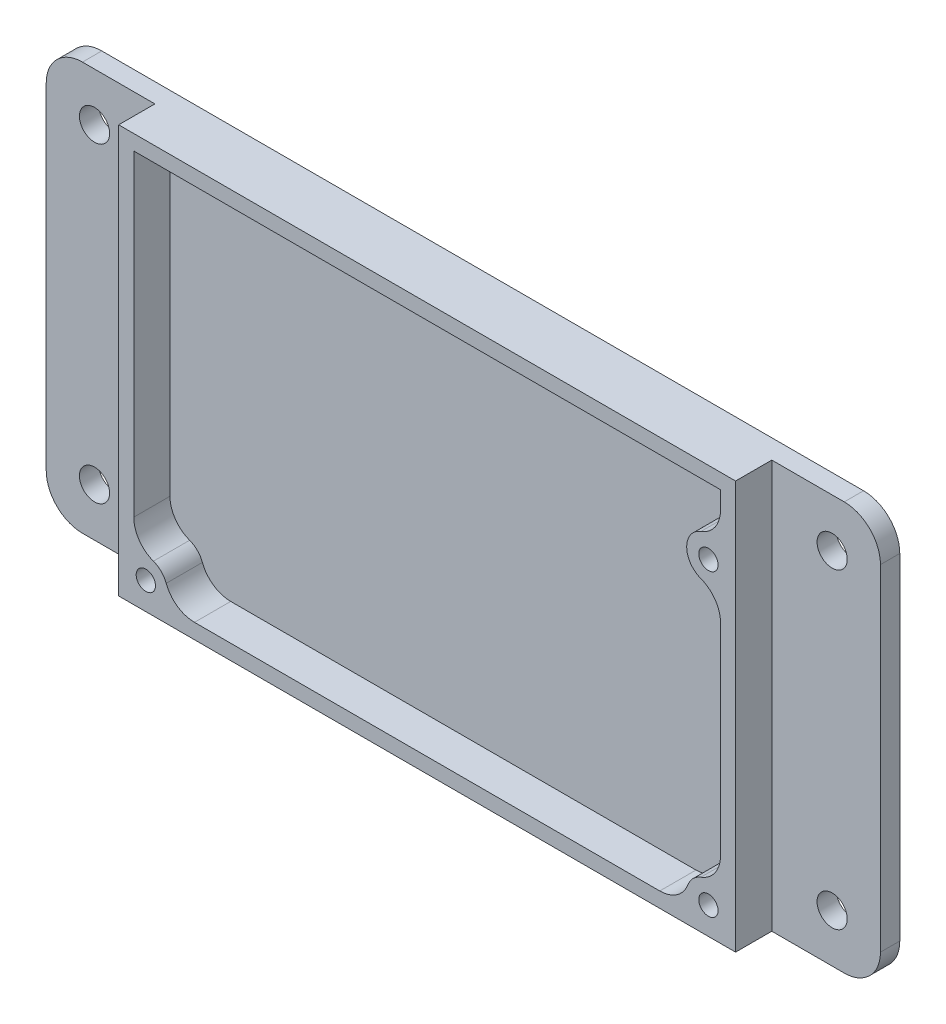
from build123d import *

# Parameters (mm, degrees)
SKETCH1_W           = 102.2
SKETCH1_H           = 67.6
SKETCH1_R           = 1.6
BOSS_EXTRUDE1_DEPTH = 6
SKETCH2_W           = 138.2
SKETCH2_H           = 67.6
SKETCH2_R           = 2.5
BOSS_EXTRUDE2_DEPTH = 3.2
FILLET1_R           = 6
FILLET2_R           = 5
FILLET3_R           = 5


with BuildPart() as part:
    # Sketch1 → Boss-Extrude1 (new body)
    with BuildSketch(Plane.XY):
        with Locations((51.1, 33.8)):
            Rectangle(SKETCH1_W, SKETCH1_H)
        with BuildLine():
            Line((94.706674091, 2.5), (7.493325909, 2.5))
            ThreePointArc((7.493325909, 2.5), (7.045584412, 7.045584412), (2.5, 7.493325909))
            Line((2.5, 7.493325909), (2.5, 65.1))
            Line((2.5, 65.1), (99.7, 65.1))
            Line((99.7, 65.1), (99.7, 57.093325909))
            ThreePointArc((99.7, 57.093325909), (94.1, 54.1), (99.7, 51.106674091))
            Line((99.7, 51.106674091), (99.7, 7.493325909))
            ThreePointArc((99.7, 7.493325909), (95.154415588, 7.045584412), (94.706674091, 2.5))
        make_face(mode=Mode.SUBTRACT)
        with Locations((4.5, 4.5)):
            Circle(SKETCH1_R, mode=Mode.SUBTRACT)
        with Locations((97.7, 4.5)):
            Circle(SKETCH1_R, mode=Mode.SUBTRACT)
        with Locations((97.7, 54.1)):
            Circle(SKETCH1_R, mode=Mode.SUBTRACT)
    extrude(amount=BOSS_EXTRUDE1_DEPTH)

    # Sketch2 → Boss-Extrude2 (add)
    with BuildSketch(Plane(origin=(0, 0, 0), x_dir=(-1, 0, 0), z_dir=(0, 0, -1))):
        with Locations((-51.1, 33.8)):
            Rectangle(SKETCH2_W, SKETCH2_H)
        with Locations((-112.2, 59.6)):
            Circle(SKETCH2_R, mode=Mode.SUBTRACT)
        with Locations((-112.2, 8)):
            Circle(SKETCH2_R, mode=Mode.SUBTRACT)
        with Locations((10, 8)):
            Circle(SKETCH2_R, mode=Mode.SUBTRACT)
        with Locations((10, 59.6)):
            Circle(SKETCH2_R, mode=Mode.SUBTRACT)
    extrude(amount=BOSS_EXTRUDE2_DEPTH)

    # Fillet1
    fillet1_edges = [part.edges().sort_by_distance(p)[0] for p in [
        (120.2, 67.6, -1.6),
        (120.2, 0, -1.6),
        (-18, 0, -1.6),
        (-18, 67.6, -1.6),
    ]]
    fillet(fillet1_edges, radius=FILLET1_R)

    # Fillet2
    fillet2_edges = [part.edges().sort_by_distance(p)[0] for p in [
        (99.7, 51.106674091, 3),
        (99.7, 57.093325909, 3),
    ]]
    fillet(fillet2_edges, radius=FILLET2_R)

    # Fillet3
    fillet3_edges = [part.edges().sort_by_distance(p)[0] for p in [
        (7.493325909, 2.5, 3),
        (94.706674091, 2.5, 3),
        (99.7, 7.493325909, 3),
        (2.5, 7.493325909, 3),
    ]]
    fillet(fillet3_edges, radius=FILLET3_R)


solid = part.part
